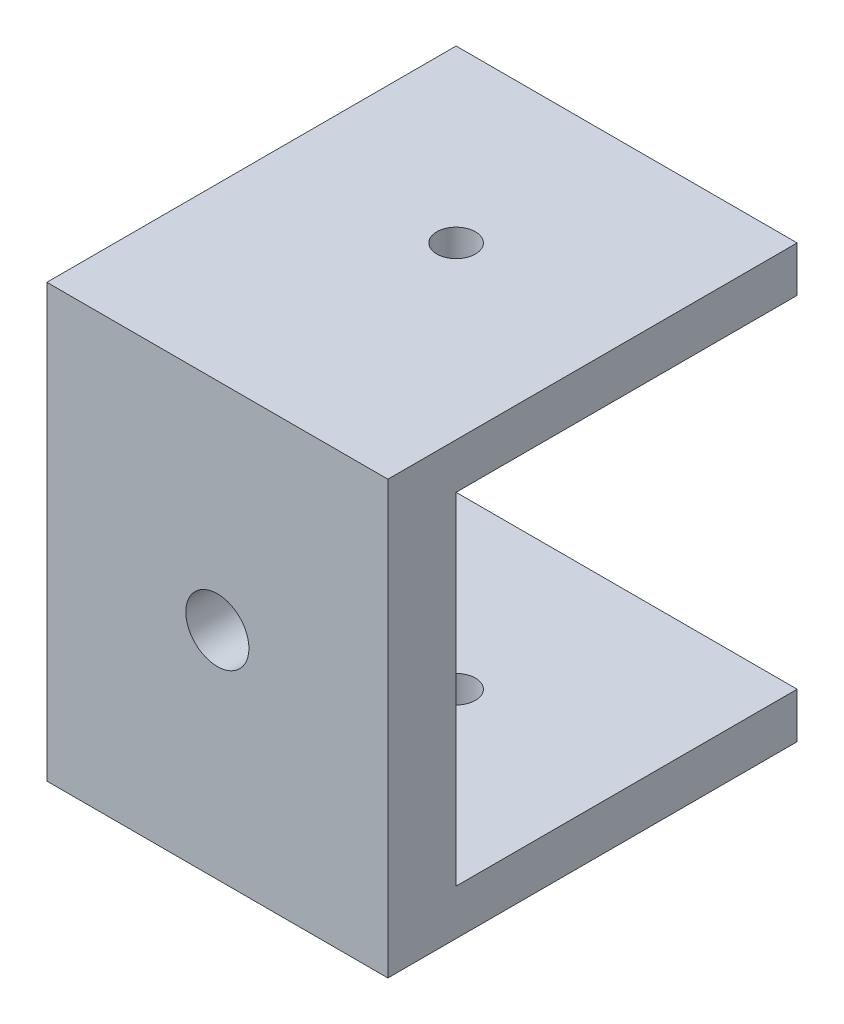
from build123d import *

# Parameters (mm, degrees)
SKETCH2_W           = 6
SKETCH2_H           = 30
BOSS_EXTRUDE1_DEPTH = 30
SKETCH4_R           = 2.775
CUT_EXTRUDE2_DEPTH  = 30
SKETCH5_R           = 1.7
CUT_EXTRUDE3_DEPTH  = 39


with BuildPart() as part:
    # Sketch2 → Boss-Extrude1 (new body)
    with BuildSketch(Plane(origin=(0, 0, 0), x_dir=(0, 0, -1), z_dir=(1, 0, 0))):
        Rectangle(SKETCH2_W, SKETCH2_H)
        Polygon((-3, 19), (-3, 15), (3, 15), (33, 15), (33, 19), align=None)
        Polygon((3, -15), (-3, -15), (-3, -19), (33, -19), (33, -15), align=None)
    extrude(amount=BOSS_EXTRUDE1_DEPTH)

    # Sketch4 → Cut-Extrude2 (cut)
    with BuildSketch(Plane.XY.offset(3)):
        with Locations((15, 0)):
            Circle(SKETCH4_R)
    extrude(amount=-CUT_EXTRUDE2_DEPTH, mode=Mode.SUBTRACT)

    # Sketch5 → Cut-Extrude3 (cut, through all)
    with BuildSketch(Plane.XZ.offset(19)):
        with Locations((15, -18)):
            Circle(SKETCH5_R)
    extrude(amount=-CUT_EXTRUDE3_DEPTH, mode=Mode.SUBTRACT)


solid = part.part
